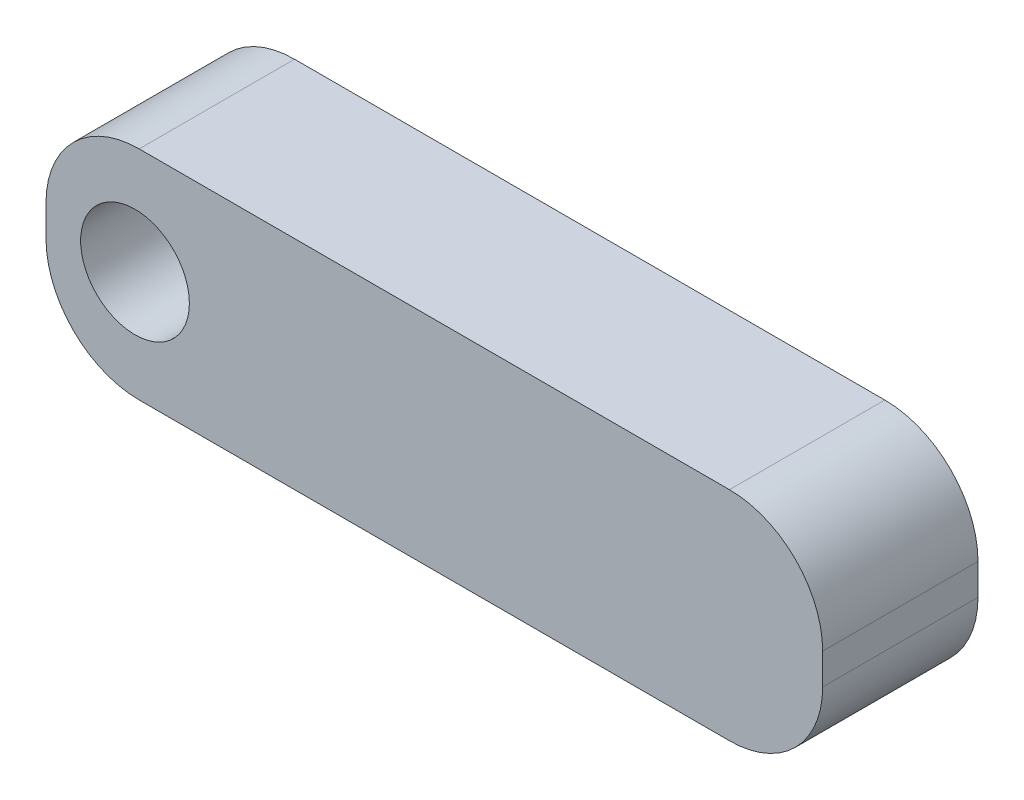
from build123d import *

# Parameters (mm, degrees)
SKETCH1_W           = 25
SKETCH1_H           = 7
SKETCH1_R           = 1.75
BOSS_EXTRUDE1_DEPTH = 5
FILLET1_R           = 3
FILLET2_R           = 3


with BuildPart() as part:
    # Sketch1 → Boss-Extrude1 (new body)
    with BuildSketch(Plane.XY):
        Rectangle(SKETCH1_W, SKETCH1_H)
        with Locations((-9.635416667, 0)):
            Circle(SKETCH1_R, mode=Mode.SUBTRACT)
    extrude(amount=BOSS_EXTRUDE1_DEPTH)

    # Fillet1
    fillet1_edges = [part.edges().sort_by_distance(p)[0] for p in [
        (-12.5, -3.5, 2.5),
        (-12.5, 3.5, 2.5),
    ]]
    fillet(fillet1_edges, radius=FILLET1_R)

    # Fillet2
    fillet2_edges = [part.edges().sort_by_distance(p)[0] for p in [
        (12.5, -3.5, 2.5),
        (12.5, 3.5, 2.5),
    ]]
    fillet(fillet2_edges, radius=FILLET2_R)


solid = part.part
